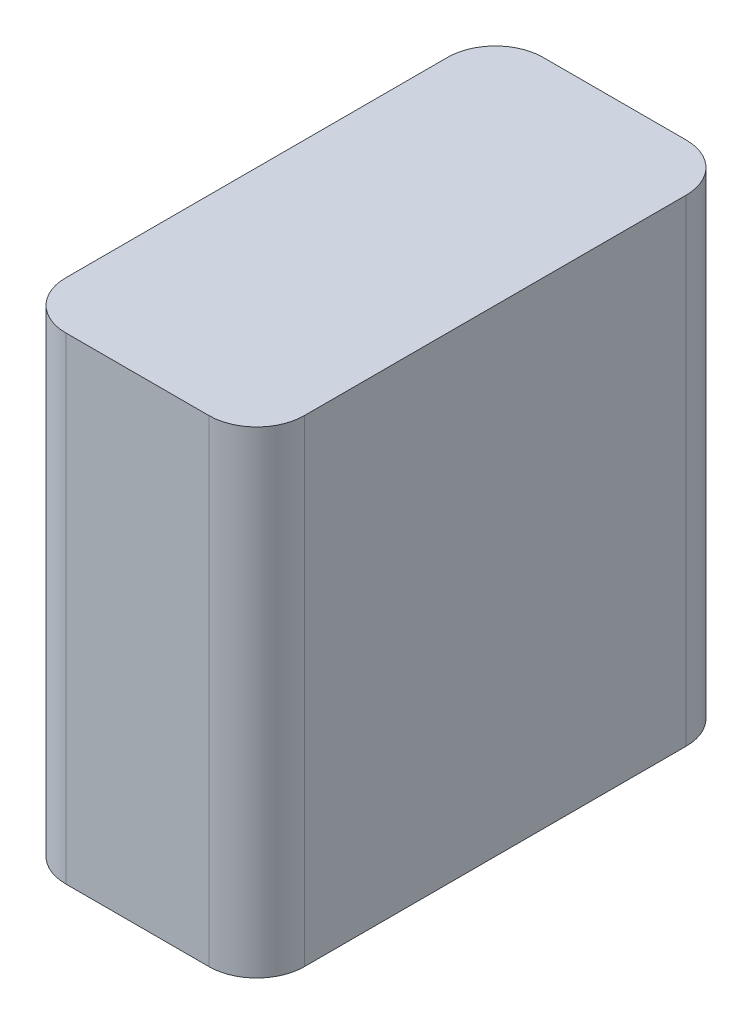
from build123d import *

# Parameters (mm, degrees)
SRECTANGLE_W     = 10
SRECTANGLE_H     = 20
FRECTANGLE_DEPTH = 20
FRRECTANGLE_R    = 2


with BuildPart() as part:
    # SRectangle → FRectangle (new body)
    with BuildSketch(Plane(origin=(0, 0, 0), x_dir=(1, 0, 0), z_dir=(0, 1, 0))):
        Rectangle(SRECTANGLE_W, SRECTANGLE_H)
    extrude(amount=-FRECTANGLE_DEPTH)

    # FRRectangle
    frrectangle_edges = [part.edges().sort_by_distance(p)[0] for p in [
        (-5, -10, -10),
        (5, -10, -10),
        (5, -10, 10),
        (-5, -10, 10),
    ]]
    fillet(frrectangle_edges, radius=FRRECTANGLE_R)


solid = part.part
